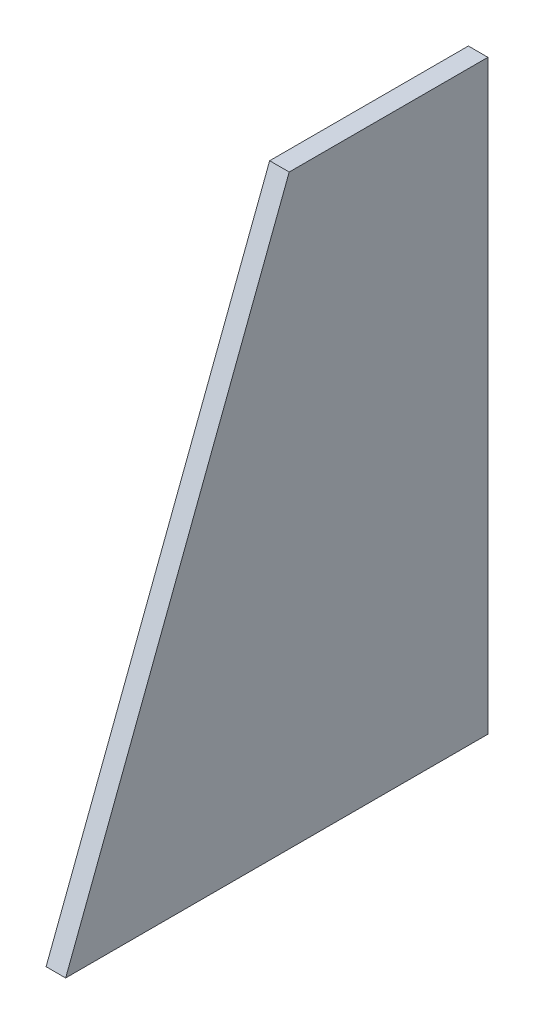
from build123d import *

# Parameters (mm, degrees)
BOSS_EXTRUDE1_DEPTH = 2.5


with BuildPart() as part:
    # Sketch1 → Boss-Extrude1 (new body, symmetric)
    with BuildSketch(Plane(origin=(0, 0, 0), x_dir=(0, 0, -1), z_dir=(1, 0, 0))):
        Polygon((0, 149.86), (0, 0), (-107.95, 0), (-50.8, 149.86), align=None)
    extrude(amount=BOSS_EXTRUDE1_DEPTH, both=True)


solid = part.part
